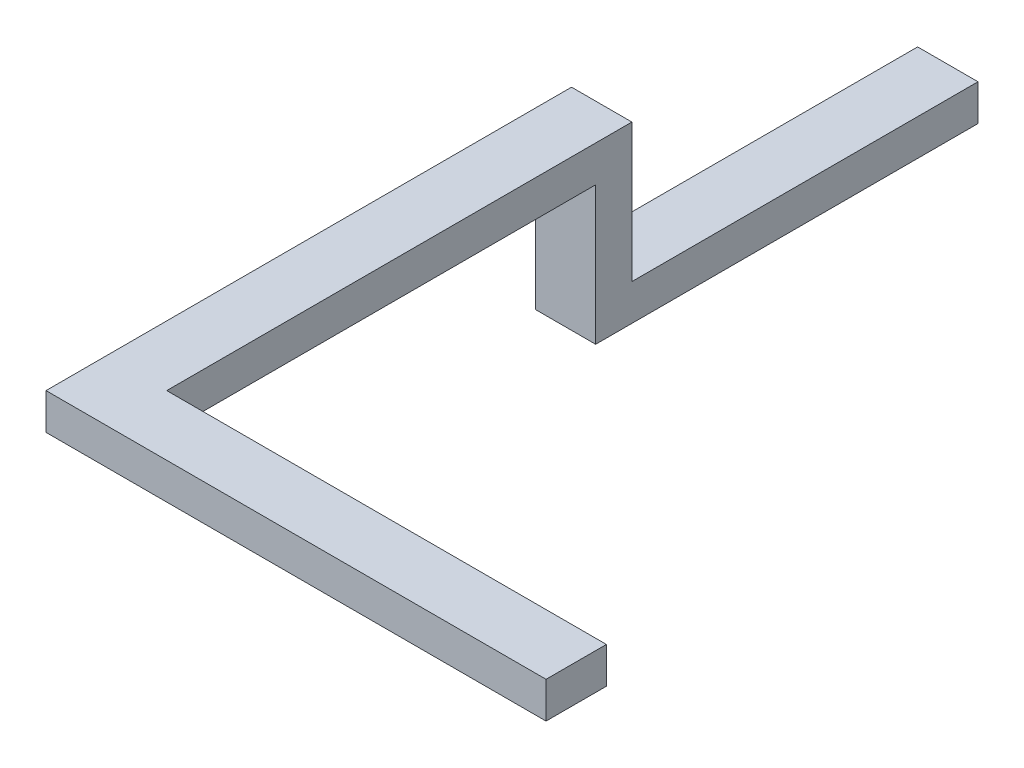
from build123d import *

# Parameters (mm, degrees)
SKETCH1_W           = 900
SKETCH1_H           = 540
SKETCH4_W           = 900
SKETCH4_H           = 540
BOSS_EXTRUDE1_DEPTH = 6555


with BuildPart() as part:
    # Sweep1: sweep along a path in Sketch2
    with BuildLine(Plane(origin=(0, 0, 0), x_dir=(0, 0, -1), z_dir=(1, 0, 0))) as sweep1_path:
        Line((0, 270), (-5430, 270))
        Line((-5430, 270), (-5430, 2330))
        Line((-5430, 2330), (-12995, 2330))
    # Sketch1 → Sweep1 (sweep)
    with BuildSketch(Plane.XY):
        with Locations((-450, 270)):
            Rectangle(SKETCH1_W, SKETCH1_H)
    sweep(path=sweep1_path.line, transition=Transition.RIGHT)

    # Sketch4 → Boss-Extrude1 (add)
    with BuildSketch(Plane(origin=(0, 0, 0), x_dir=(0, 0, -1), z_dir=(1, 0, 0))):
        with Locations((-12545, 2330)):
            Rectangle(SKETCH4_W, SKETCH4_H)
    extrude(amount=BOSS_EXTRUDE1_DEPTH)


solid = part.part
